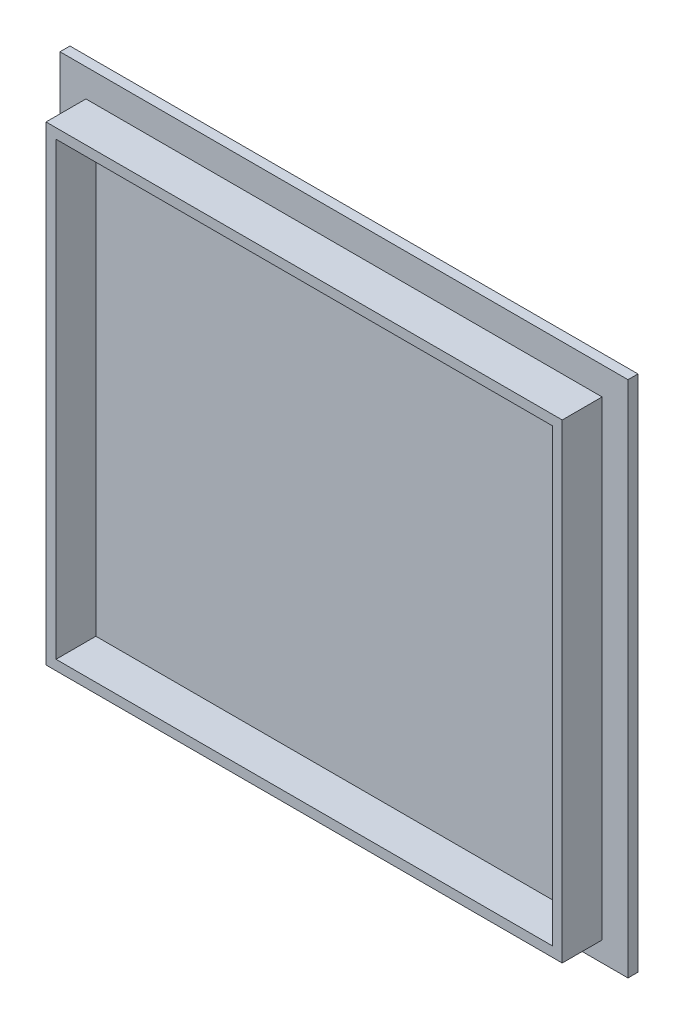
from build123d import *

# Parameters (mm, degrees)
SKETCH1_W           = 285
SKETCH1_H           = 260
BOSS_EXTRUDE3_DEPTH = 5
SKETCH3_W           = 259
SKETCH3_H           = 236
BOSS_EXTRUDE4_DEPTH = 20
SKETCH4_W           = 249
SKETCH4_H           = 226
CUT_EXTRUDE1_DEPTH  = 20


with BuildPart() as part:
    # Sketch1 → Boss-Extrude3 (new body)
    with BuildSketch(Plane.XY):
        with Locations((20.685479664, 43.047709924)):
            Rectangle(SKETCH1_W, SKETCH1_H)
    extrude(amount=BOSS_EXTRUDE3_DEPTH)

    # Sketch3 → Boss-Extrude4 (add)
    with BuildSketch(Plane.XY.offset(5)):
        with Locations((20.685479664, 41.047709924)):
            Rectangle(SKETCH3_W, SKETCH3_H)
    extrude(amount=BOSS_EXTRUDE4_DEPTH)

    # Sketch4 → Cut-Extrude1 (cut)
    with BuildSketch(Plane.XY.offset(25)):
        with Locations((20.685479664, 41.047709924)):
            Rectangle(SKETCH4_W, SKETCH4_H)
    extrude(amount=-CUT_EXTRUDE1_DEPTH, mode=Mode.SUBTRACT)


solid = part.part
